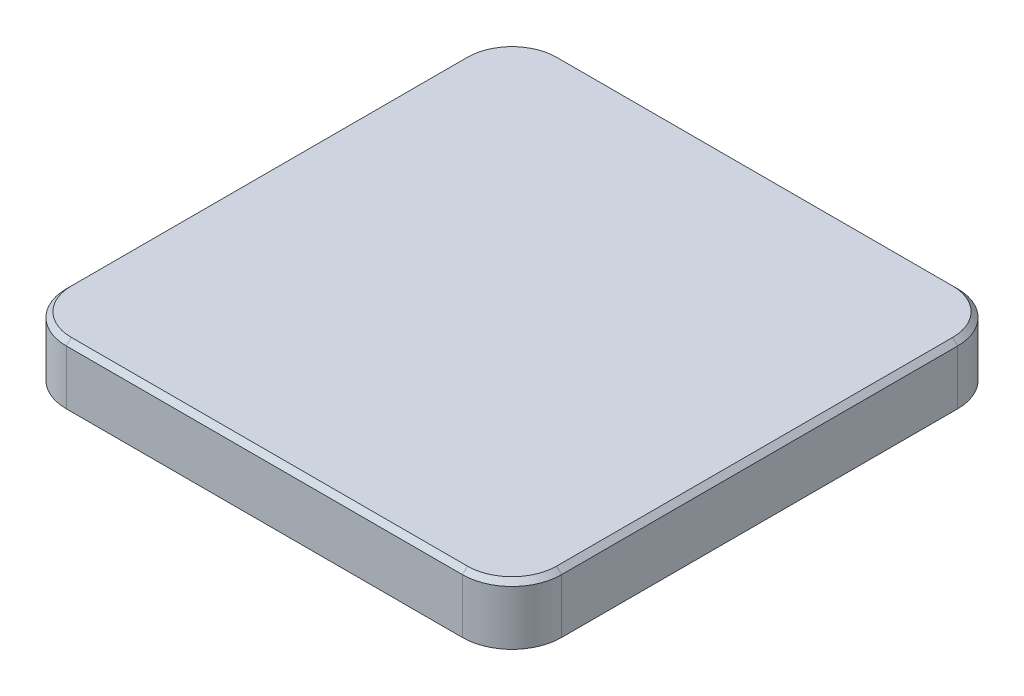
from build123d import *

# Parameters (mm, degrees)
SALIENTE_EXTRUIR1_DEPTH = 12
CHAFL_N1_SIZE           = 1


with BuildPart() as part:
    # Croquis2 → Saliente-Extruir1 (new body)
    with BuildSketch(Plane(origin=(0, 0, 0), x_dir=(1, 0, 0), z_dir=(0, 1, 0))):
        with BuildLine():
            Line((-40, 50), (40, 50))
            ThreePointArc((40, 50), (47.071067812, 47.071067812), (50, 40))
            Line((50, 40), (50, -40))
            ThreePointArc((50, -40), (47.071067812, -47.071067812), (40, -50))
            Line((40, -50), (-40, -50))
            ThreePointArc((-40, -50), (-47.071067812, -47.071067812), (-50, -40))
            Line((-50, -40), (-50, 40))
            ThreePointArc((-50, 40), (-47.071067812, 47.071067812), (-40, 50))
        make_face()
    extrude(amount=SALIENTE_EXTRUIR1_DEPTH)

    # Chaflán1
    chafl_n1_edges = [part.edges().sort_by_distance(p)[0] for p in [
        (-47.071067812, 12, -47.071067812),
        (-50, 12, 0),
        (-47.071067812, 12, 47.071067812),
        (0, 12, 50),
        (47.071067812, 12, 47.071067812),
        (50, 12, 0),
        (47.071067812, 12, -47.071067812),
        (0, 12, -50),
    ]]
    chamfer(chafl_n1_edges, length=CHAFL_N1_SIZE)


solid = part.part
